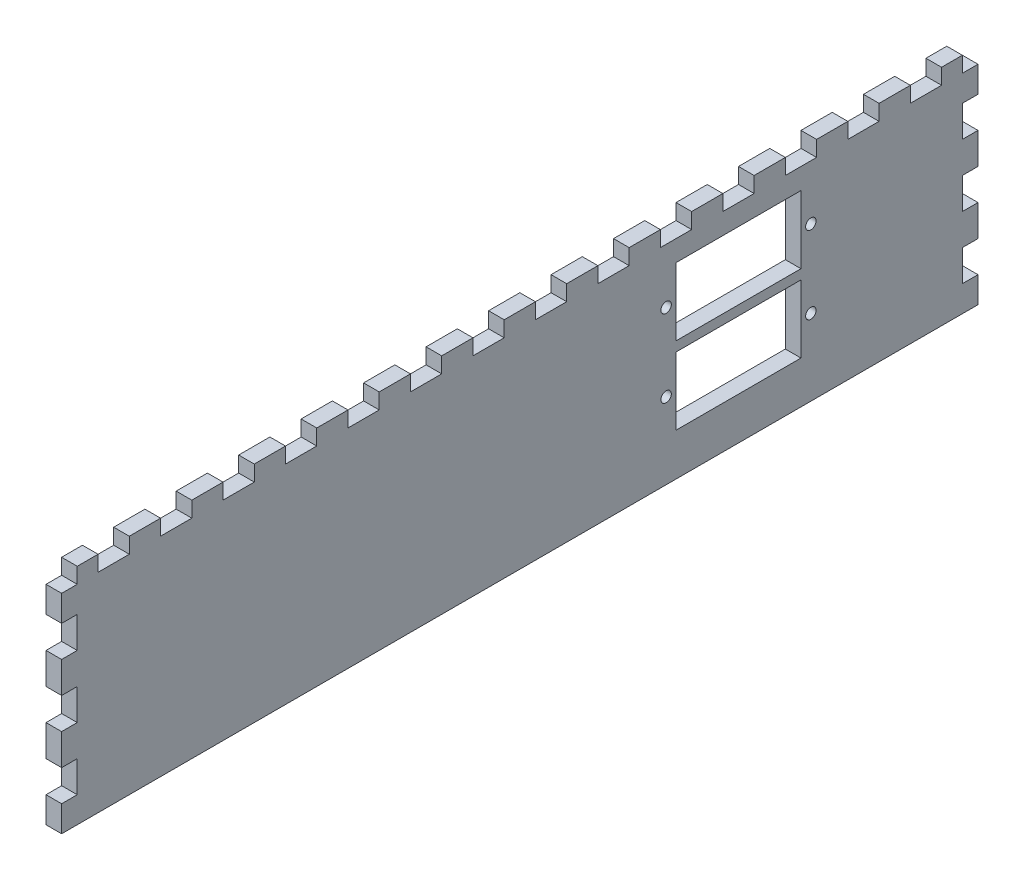
from build123d import *

# Parameters (mm, degrees)
SKETCH1_W               = 170
SKETCH1_H               = 40
BOSS_EXTRUDE1_DEPTH     = 3
SKETCH3_W               = 3
SKETCH3_H               = 6
BOSS_EXTRUDE2_DEPTH     = 3
LPATTERN1_COUNT         = 3
LPATTERN1_PITCH         = 12
LPATTERN1_COL_COUNT     = 2
LPATTERN1_COL_PITCH     = 12
SKETCH4_W               = 3
SKETCH4_H               = 6
BOSS_EXTRUDE3_DEPTH     = 3
LPATTERN2_COUNT         = 8
LPATTERN2_PITCH         = 12
LPATTERN2_COL_COUNT     = 8
LPATTERN2_COL_PITCH     = 12
MIRROR1_COPY_1_SKETCH_W = 3
MIRROR1_COPY_1_SKETCH_H = 6
MIRROR1_COPY_1_DEPTH    = 3
MIRROR1_COPY_2_SKETCH_W = 3
MIRROR1_COPY_2_SKETCH_H = 6
MIRROR1_COPY_2_DEPTH    = 3
MIRROR1_COPY_3_SKETCH_W = 3
MIRROR1_COPY_3_SKETCH_H = 6
MIRROR1_COPY_3_DEPTH    = 3
SKETCH6_R               = 1
SKETCH6_W               = 24
SKETCH6_H               = 13
CUT_EXTRUDE2_DEPTH      = 4
SKETCH7_W               = 3
SKETCH7_H               = 3
CUT_EXTRUDE4_DEPTH      = 4
SKETCH8_W               = 3
SKETCH8_H               = 1
CUT_EXTRUDE5_DEPTH      = 3


with BuildPart() as part:
    # Sketch1 → Boss-Extrude1 (new body)
    with BuildSketch(Plane(origin=(0, 0, 0), x_dir=(0, 0, -1), z_dir=(1, 0, 0))):
        Rectangle(SKETCH1_W, SKETCH1_H)
    extrude(amount=BOSS_EXTRUDE1_DEPTH)

    # Sketch3 → Boss-Extrude2 (add)
    with BuildSketch(Plane(origin=(0, 0, -85), x_dir=(-1, 0, 0), z_dir=(0, 0, -1))):
        with Locations((-1.5, 6)):
            Rectangle(SKETCH3_W, SKETCH3_H)
    boss_extrude2 = extrude(amount=BOSS_EXTRUDE2_DEPTH)

    # LPattern1: Boss-Extrude2 ×3
    with Locations(*[(0, -i * LPATTERN1_PITCH, 0) for i in range(1, LPATTERN1_COUNT)]):
        add(boss_extrude2)

    # LPattern1 col: Boss-Extrude2 ×2
    with Locations(*[(0, i * LPATTERN1_COL_PITCH, 0) for i in range(1, LPATTERN1_COL_COUNT)]):
        add(boss_extrude2)

    # Sketch4 → Boss-Extrude3 (add)
    with BuildSketch(Plane(origin=(0, 20, 0), x_dir=(1, 0, 0), z_dir=(0, 1, 0))):
        with Locations((1.5, 0)):
            Rectangle(SKETCH4_W, SKETCH4_H)
    boss_extrude3 = extrude(amount=BOSS_EXTRUDE3_DEPTH)

    # LPattern2: Boss-Extrude3 ×8
    with Locations(*[(0, 0, -i * LPATTERN2_PITCH) for i in range(1, LPATTERN2_COUNT)]):
        add(boss_extrude3)

    # LPattern2 col: Boss-Extrude3 ×8
    with Locations(*[(0, 0, i * LPATTERN2_COL_PITCH) for i in range(1, LPATTERN2_COL_COUNT)]):
        add(boss_extrude3)

    # Mirror1: Boss-Extrude2 across plane
    add(boss_extrude2.mirror(Plane.XY))

    # Mirror1 copy 1 sketch → Mirror1 copy 1 (add)
    with BuildSketch(Plane(origin=(0, -12, 85), x_dir=(-1, 0, 0), z_dir=(0, 0, 1))):
        with Locations((-1.5, -6)):
            Rectangle(MIRROR1_COPY_1_SKETCH_W, MIRROR1_COPY_1_SKETCH_H)
    extrude(amount=MIRROR1_COPY_1_DEPTH)

    # Mirror1 copy 2 sketch → Mirror1 copy 2 (add)
    with BuildSketch(Plane(origin=(0, -24, 85), x_dir=(-1, 0, 0), z_dir=(0, 0, 1))):
        with Locations((-1.5, -6)):
            Rectangle(MIRROR1_COPY_2_SKETCH_W, MIRROR1_COPY_2_SKETCH_H)
    extrude(amount=MIRROR1_COPY_2_DEPTH)

    # Mirror1 copy 3 sketch → Mirror1 copy 3 (add)
    with BuildSketch(Plane(origin=(0, 12, 85), x_dir=(-1, 0, 0), z_dir=(0, 0, 1))):
        with Locations((-1.5, -6)):
            Rectangle(MIRROR1_COPY_3_SKETCH_W, MIRROR1_COPY_3_SKETCH_H)
    extrude(amount=MIRROR1_COPY_3_DEPTH)

    # Sketch6 → Cut-Extrude2 (cut, through all)
    with BuildSketch(Plane(origin=(3, 0, 0), x_dir=(0, 0, -1), z_dir=(1, 0, 0))):
        with Locations((28.1, -5.368175576)):
            Circle(SKETCH6_R)
        with Locations((55.9, -5.368175576)):
            Circle(SKETCH6_R)
        with Locations((28.1, 9.494198583)):
            Circle(SKETCH6_R)
        with Locations((55.9, 9.494198583)):
            Circle(SKETCH6_R)
        with Locations((42, -5.368175576)):
            Rectangle(SKETCH6_W, SKETCH6_H)
        with Locations((42, 9.494198583)):
            Rectangle(SKETCH6_W, SKETCH6_H)
    extrude(amount=-CUT_EXTRUDE2_DEPTH, mode=Mode.SUBTRACT)

    # Sketch7 → Cut-Extrude4 (cut, through all)
    with BuildSketch(Plane(origin=(3, 0, 0), x_dir=(0, 0, -1), z_dir=(1, 0, 0))):
        with Locations((86.5, 21.5)):
            Rectangle(SKETCH7_W, SKETCH7_H)
    cut_extrude4 = extrude(amount=-CUT_EXTRUDE4_DEPTH, mode=Mode.SUBTRACT)

    # Mirror2: Cut-Extrude4 across plane
    add(cut_extrude4.mirror(Plane.XY), mode=Mode.SUBTRACT)

    # Sketch8 → Cut-Extrude5 (cut)
    with BuildSketch(Plane.ZY):
        with Locations((86.5, -20.5)):
            Rectangle(SKETCH8_W, SKETCH8_H)
    cut_extrude5 = extrude(amount=-CUT_EXTRUDE5_DEPTH, mode=Mode.SUBTRACT)

    # Mirror3: Cut-Extrude5 across plane
    add(cut_extrude5.mirror(Plane.XY), mode=Mode.SUBTRACT)


solid = part.part
